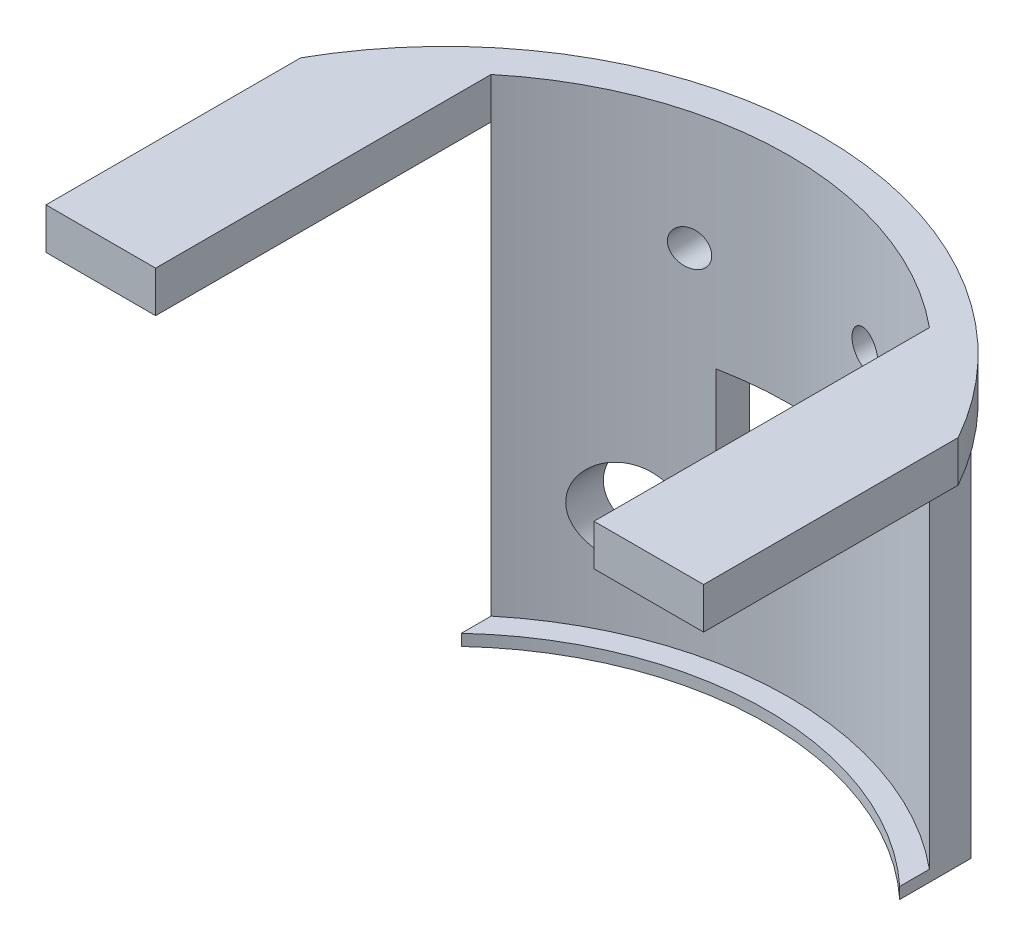
from build123d import *

# Parameters (mm, degrees)
BOSS_EXTRUDE1_DEPTH = 54.8
CUT_EXTRUDE1_DEPTH  = 53.5
CUT_EXTRUDE2_DEPTH  = 50.1
CUT_EXTRUDE4_REACH  = 53
SKETCH5_R           = 2
SKETCH5_R_2         = 5
SKETCH5_W           = 15.2
SKETCH5_H           = 9
SKETCH6_R           = 36.7
CUT_EXTRUDE5_DEPTH  = 10


with BuildPart() as part:
    # Sketch2 → Boss-Extrude1 (new body)
    with BuildSketch(Plane(origin=(0, 0, 0), x_dir=(1, 0, 0), z_dir=(0, 1, 0))):
        with BuildLine():
            Line((-37.5, 21.041625413), (-37.5, -8))
            Line((-37.5, -8), (37.5, -8))
            Line((37.5, -8), (37.5, 21.041625413))
            ThreePointArc((37.5, 21.041625413), (0, 43), (-37.5, 21.041625413))
        make_face()
    extrude(amount=BOSS_EXTRUDE1_DEPTH)

    # Sketch3 → Cut-Extrude1 (cut)
    with BuildSketch(Plane(origin=(0, 54.8, 0), x_dir=(1, 0, 0), z_dir=(0, 1, 0))):
        with BuildLine():
            Line((-25, 30.258263334), (-25, -8))
            Line((-25, -8), (25, -8))
            Line((25, -8), (25, 30.258263334))
            ThreePointArc((25, 30.258263334), (0, 39.25), (-25, 30.258263334))
        make_face()
    extrude(amount=-CUT_EXTRUDE1_DEPTH, mode=Mode.SUBTRACT)

    # Sketch4 → Cut-Extrude2 (cut)
    with BuildSketch(Plane.XZ):
        with BuildLine():
            Line((25, 8), (25, -34.985711369))
            ThreePointArc((25, -34.985711369), (32.018305441, -28.702406114), (37.5, -21.041625413))
            Line((37.5, -21.041625413), (37.5, 8))
            Line((37.5, 8), (25, 8))
        make_face()
        with BuildLine():
            Line((-25, 8), (-25, -34.985711369))
            ThreePointArc((-25, -34.985711369), (-32.018305441, -28.702406114), (-37.5, -21.041625413))
            Line((-37.5, -21.041625413), (-37.5, 8))
            Line((-37.5, 8), (-25, 8))
        make_face()
    extrude(amount=-CUT_EXTRUDE2_DEPTH, mode=Mode.SUBTRACT)

    # Sketch5 → Cut-Extrude4 (cut, up to next)
    with BuildSketch(Plane.XY.offset(8), mode=Mode.PRIVATE) as cut_extrude4_sk1:
        with Locations((-10, 41.3)):
            Circle(SKETCH5_R)
    cut_extrude4_tool1 = extrude(cut_extrude4_sk1.sketch, amount=-CUT_EXTRUDE4_REACH, mode=Mode.PRIVATE) & part.part
    add(cut_extrude4_tool1.solids().sort_by_distance((-10, 41.3, 8))[0], mode=Mode.SUBTRACT)
    # Sketch5 → Cut-Extrude4 (cut, up to next)
    with BuildSketch(Plane.XY.offset(8), mode=Mode.PRIVATE) as cut_extrude4_sk2:
        with Locations((10, 41.3)):
            Circle(SKETCH5_R)
    cut_extrude4_tool2 = extrude(cut_extrude4_sk2.sketch, amount=-CUT_EXTRUDE4_REACH, mode=Mode.PRIVATE) & part.part
    add(cut_extrude4_tool2.solids().sort_by_distance((10, 41.3, 8))[0], mode=Mode.SUBTRACT)
    # Sketch5 → Cut-Extrude4 (cut, up to next)
    with BuildSketch(Plane.XY.offset(8), mode=Mode.PRIVATE) as cut_extrude4_sk3:
        with Locations((-15, 13.3)):
            Circle(SKETCH5_R_2)
    cut_extrude4_tool3 = extrude(cut_extrude4_sk3.sketch, amount=-CUT_EXTRUDE4_REACH, mode=Mode.PRIVATE) & part.part
    add(cut_extrude4_tool3.solids().sort_by_distance((-15, 13.3, 8))[0], mode=Mode.SUBTRACT)
    # Sketch5 → Cut-Extrude4 (cut, up to next)
    with BuildSketch(Plane.XY.offset(8), mode=Mode.PRIVATE) as cut_extrude4_sk4:
        with Locations((0, 25.8)):
            Rectangle(SKETCH5_W, SKETCH5_H)
    cut_extrude4_tool4 = extrude(cut_extrude4_sk4.sketch, amount=-CUT_EXTRUDE4_REACH, mode=Mode.PRIVATE) & part.part
    add(cut_extrude4_tool4.solids().sort_by_distance((0, 25.8, 8))[0], mode=Mode.SUBTRACT)

    # Sketch6 → Cut-Extrude5 (cut)
    with BuildSketch(Plane(origin=(0, 1.3, 0), x_dir=(1, 0, 0), z_dir=(0, 1, 0))):
        Circle(SKETCH6_R)
    extrude(amount=-CUT_EXTRUDE5_DEPTH, mode=Mode.SUBTRACT)


solid = part.part
